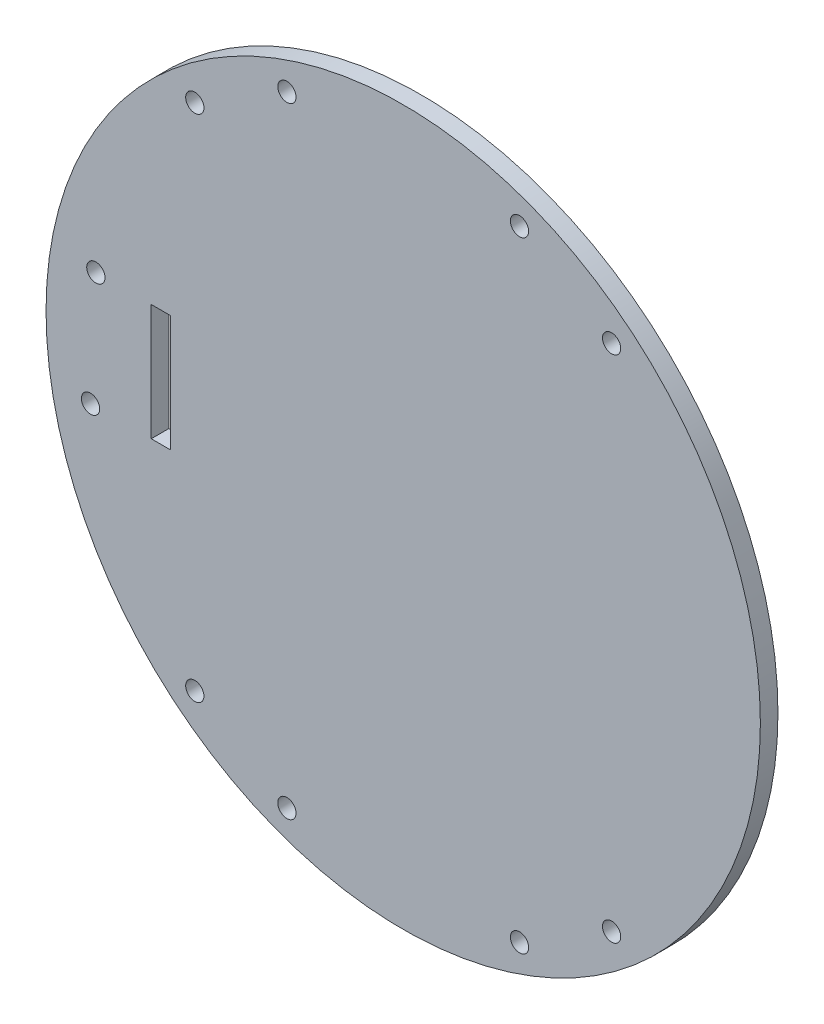
from build123d import *

# Parameters (mm, degrees)
SKETCH1_R           = 64.5
SKETCH1_R_2         = 1.65
SKETCH1_W           = 3.5
SKETCH1_H           = 21
BOSS_EXTRUDE1_DEPTH = 3.175


with BuildPart() as part:
    # Sketch1 → Boss-Extrude1 (new body)
    with BuildSketch(Plane(origin=(0, 0, 0), x_dir=(-1, 0, 0), z_dir=(0, 0, 1))):
        with Locations((14.94226781, -5.633574242)):
            Circle(SKETCH1_R)
        with Locations((-6.05773219, 50.366425758)):
            Circle(SKETCH1_R_2, mode=Mode.SUBTRACT)
        with Locations((-22.69188657, 40.366425758)):
            Circle(SKETCH1_R_2, mode=Mode.SUBTRACT)
        with Locations((35.94226781, 50.366425758)):
            Circle(SKETCH1_R_2, mode=Mode.SUBTRACT)
        with Locations((52.57642219, 40.366425758)):
            Circle(SKETCH1_R_2, mode=Mode.SUBTRACT)
        with Locations((52.57642219, -51.633574242)):
            Circle(SKETCH1_R_2, mode=Mode.SUBTRACT)
        with Locations((35.94226781, -61.633574242)):
            Circle(SKETCH1_R_2, mode=Mode.SUBTRACT)
        with Locations((-6.05773219, -61.633574242)):
            Circle(SKETCH1_R_2, mode=Mode.SUBTRACT)
        with Locations((-22.69188657, -51.633574242)):
            Circle(SKETCH1_R_2, mode=Mode.SUBTRACT)
        with Locations((71.403979127, 4.866425758)):
            Circle(SKETCH1_R_2, mode=Mode.SUBTRACT)
        with Locations((70.44226781, -16.133574242)):
            Circle(SKETCH1_R_2, mode=Mode.SUBTRACT)
        with Locations((58.69226781, -5.633574242)):
            Rectangle(SKETCH1_W, SKETCH1_H, mode=Mode.SUBTRACT)
    extrude(amount=BOSS_EXTRUDE1_DEPTH)


solid = part.part
